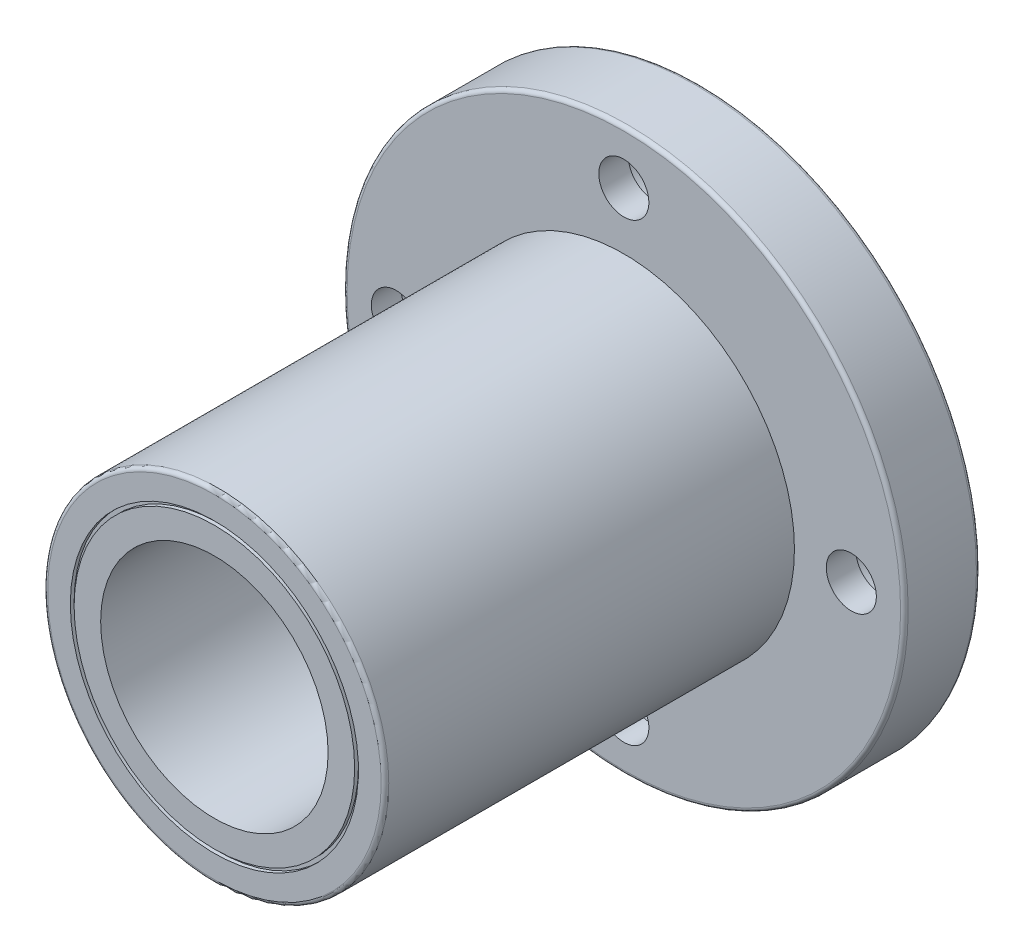
from build123d import *

# Parameters (mm, degrees)
PADR_OCIRCULAR1_COUNT = 4
FILETE1_R             = 0.5


with BuildPart() as part:
    # Esboço1 → Revolução1 (revolve)
    with BuildSketch(Plane(origin=(0, 0, 0), x_dir=(0, 0, -1), z_dir=(1, 0, 0)), mode=Mode.PRIVATE) as revolu_o1_sk:
        Polygon((0, 15), (0, 18.5), (-0.5, 18.5), (-0.5, 19), (0, 19), (0, 22), (-0.5, 22), (-0.5, 22.5), (0, 22.5), (0, 37), (-10, 37), (-10, 22.5), (-64, 22.5), (-64, 19), (-63.5, 19), (-63.5, 18.5), (-64, 18.5), (-64, 15), align=None)
    revolve(revolu_o1_sk.sketch.rotate(Axis((0, 0, 0), (0, 0, 1)), 90), axis=Axis((0, 0, 0), (0, 0, 1)))  # turned: the seam where the file's is

    # Esboço5 → Corte-Revolução1 (revolve, cut)
    with BuildSketch(Plane(origin=(0, 0, 0), x_dir=(0, 0, -1), z_dir=(1, 0, 0)), mode=Mode.PRIVATE) as corte_revolu_o1_sk:
        Polygon((0, 35.5), (-6.1, 35.5), (-6.1, 33.3), (-10, 33.3), (-10, 30), (0, 30), align=None)
    corte_revolu_o1 = revolve(corte_revolu_o1_sk.sketch.rotate(Axis((0, 30, 0), (0, 0, -1)), 180), axis=Axis((0, 30, 0), (0, 0, -1)), mode=Mode.SUBTRACT)  # turned: the seam where the file's is

    # PadrãoCircular1: Corte-Revolução1 ×4 about axis
    padr_ocircular1_axis = Axis((0, 0, 0), (0, 0, 1))
    for i in range(1, PADR_OCIRCULAR1_COUNT):
        add(corte_revolu_o1.rotate(padr_ocircular1_axis, i * 360 / PADR_OCIRCULAR1_COUNT), mode=Mode.SUBTRACT)

    # Filete1
    filete1_edges = [part.edges().sort_by_distance(p)[0] for p in [
        (22.5, 0, 64),
        (37, 0, 10),
        (37, 0, 0),
    ]]
    fillet(filete1_edges, radius=FILETE1_R)


solid = part.part
